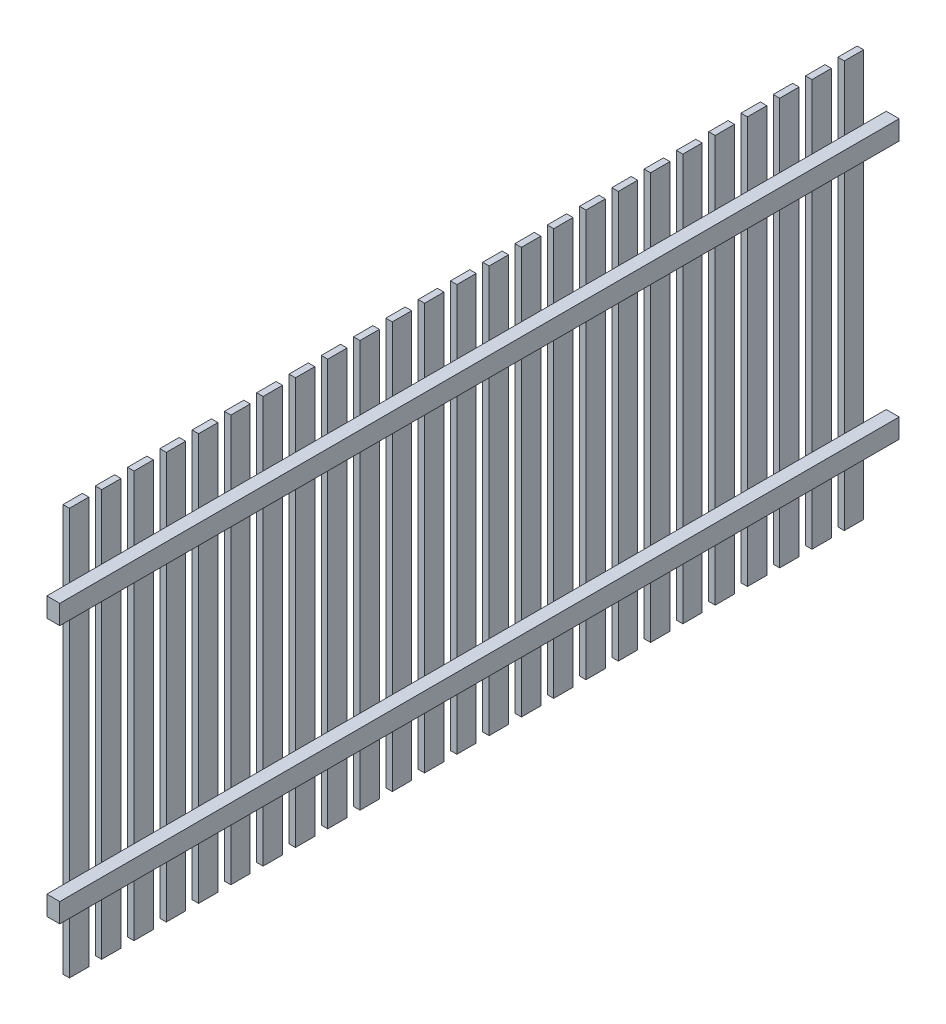
from build123d import *

# Parameters (mm, degrees)
SKIZZE1_W                       = 40
SKIZZE1_H                       = 60
AUFSATZ_LINEAR_AUSTRAGEN1_DEPTH = 1300
LINEARES_MUSTER1_COUNT          = 2
LINEARES_MUSTER1_PITCH          = 800
SKIZZE2_W                       = 60
SKIZZE2_H                       = 1260
AUFSATZ_LINEAR_AUSTRAGEN2_DEPTH = 20
LINEARES_MUSTER2_COUNT          = 13
LINEARES_MUSTER2_PITCH          = 100
LINEARES_MUSTER2_2_COUNT        = 13
LINEARES_MUSTER2_2_PITCH        = 100


with BuildPart() as part:
    # Skizze1 → Aufsatz-Linear austragen1 (new body, symmetric)
    with BuildSketch(Plane.XY):
        with Locations((20, 30)):
            Rectangle(SKIZZE1_W, SKIZZE1_H)
    extrude(amount=AUFSATZ_LINEAR_AUSTRAGEN1_DEPTH, both=True)


with BuildPart() as lineares_muster1_1:
    # Lineares Muster1: pattern copy
    add(part.part.moved(Location(Vector(0, 1, 0) * (1 * LINEARES_MUSTER1_PITCH))))


with BuildPart() as body_3:
    # Skizze2 → Aufsatz-Linear austragen2 (new body)
    with BuildSketch(Plane.ZY):
        with Locations((0, 430)):
            Rectangle(SKIZZE2_W, SKIZZE2_H)
    extrude(amount=AUFSATZ_LINEAR_AUSTRAGEN2_DEPTH)


with BuildPart() as lineares_muster2_1:
    # Lineares Muster2: pattern copy
    add(body_3.part.moved(Location(Vector(0, 0, 1) * (1 * LINEARES_MUSTER2_PITCH))))


with BuildPart() as lineares_muster2_2:
    # Lineares Muster2: pattern copy
    add(body_3.part.moved(Location(Vector(0, 0, 1) * (2 * LINEARES_MUSTER2_PITCH))))


with BuildPart() as lineares_muster2_3:
    # Lineares Muster2: pattern copy
    add(body_3.part.moved(Location(Vector(0, 0, 1) * (3 * LINEARES_MUSTER2_PITCH))))


with BuildPart() as lineares_muster2_4:
    # Lineares Muster2: pattern copy
    add(body_3.part.moved(Location(Vector(0, 0, 1) * (4 * LINEARES_MUSTER2_PITCH))))


with BuildPart() as lineares_muster2_5:
    # Lineares Muster2: pattern copy
    add(body_3.part.moved(Location(Vector(0, 0, 1) * (5 * LINEARES_MUSTER2_PITCH))))


with BuildPart() as lineares_muster2_6:
    # Lineares Muster2: pattern copy
    add(body_3.part.moved(Location(Vector(0, 0, 1) * (6 * LINEARES_MUSTER2_PITCH))))


with BuildPart() as lineares_muster2_7:
    # Lineares Muster2: pattern copy
    add(body_3.part.moved(Location(Vector(0, 0, 1) * (7 * LINEARES_MUSTER2_PITCH))))


with BuildPart() as lineares_muster2_8:
    # Lineares Muster2: pattern copy
    add(body_3.part.moved(Location(Vector(0, 0, 1) * (8 * LINEARES_MUSTER2_PITCH))))


with BuildPart() as lineares_muster2_9:
    # Lineares Muster2: pattern copy
    add(body_3.part.moved(Location(Vector(0, 0, 1) * (9 * LINEARES_MUSTER2_PITCH))))


with BuildPart() as lineares_muster2_10:
    # Lineares Muster2: pattern copy
    add(body_3.part.moved(Location(Vector(0, 0, 1) * (10 * LINEARES_MUSTER2_PITCH))))


with BuildPart() as lineares_muster2_11:
    # Lineares Muster2: pattern copy
    add(body_3.part.moved(Location(Vector(0, 0, 1) * (11 * LINEARES_MUSTER2_PITCH))))


with BuildPart() as lineares_muster2_12:
    # Lineares Muster2: pattern copy
    add(body_3.part.moved(Location(Vector(0, 0, 1) * (12 * LINEARES_MUSTER2_PITCH))))


with BuildPart() as lineares_muster2_2_1:
    # Lineares Muster2 2: pattern copy
    add(body_3.part.moved(Location(Vector(0, 0, -1) * (1 * LINEARES_MUSTER2_2_PITCH))))


with BuildPart() as lineares_muster2_2_2:
    # Lineares Muster2 2: pattern copy
    add(body_3.part.moved(Location(Vector(0, 0, -1) * (2 * LINEARES_MUSTER2_2_PITCH))))


with BuildPart() as lineares_muster2_2_3:
    # Lineares Muster2 2: pattern copy
    add(body_3.part.moved(Location(Vector(0, 0, -1) * (3 * LINEARES_MUSTER2_2_PITCH))))


with BuildPart() as lineares_muster2_2_4:
    # Lineares Muster2 2: pattern copy
    add(body_3.part.moved(Location(Vector(0, 0, -1) * (4 * LINEARES_MUSTER2_2_PITCH))))


with BuildPart() as lineares_muster2_2_5:
    # Lineares Muster2 2: pattern copy
    add(body_3.part.moved(Location(Vector(0, 0, -1) * (5 * LINEARES_MUSTER2_2_PITCH))))


with BuildPart() as lineares_muster2_2_6:
    # Lineares Muster2 2: pattern copy
    add(body_3.part.moved(Location(Vector(0, 0, -1) * (6 * LINEARES_MUSTER2_2_PITCH))))


with BuildPart() as lineares_muster2_2_7:
    # Lineares Muster2 2: pattern copy
    add(body_3.part.moved(Location(Vector(0, 0, -1) * (7 * LINEARES_MUSTER2_2_PITCH))))


with BuildPart() as lineares_muster2_2_8:
    # Lineares Muster2 2: pattern copy
    add(body_3.part.moved(Location(Vector(0, 0, -1) * (8 * LINEARES_MUSTER2_2_PITCH))))


with BuildPart() as lineares_muster2_2_9:
    # Lineares Muster2 2: pattern copy
    add(body_3.part.moved(Location(Vector(0, 0, -1) * (9 * LINEARES_MUSTER2_2_PITCH))))


with BuildPart() as lineares_muster2_2_10:
    # Lineares Muster2 2: pattern copy
    add(body_3.part.moved(Location(Vector(0, 0, -1) * (10 * LINEARES_MUSTER2_2_PITCH))))


with BuildPart() as lineares_muster2_2_11:
    # Lineares Muster2 2: pattern copy
    add(body_3.part.moved(Location(Vector(0, 0, -1) * (11 * LINEARES_MUSTER2_2_PITCH))))


with BuildPart() as lineares_muster2_2_12:
    # Lineares Muster2 2: pattern copy
    add(body_3.part.moved(Location(Vector(0, 0, -1) * (12 * LINEARES_MUSTER2_2_PITCH))))


solid = Compound([part.part, lineares_muster1_1.part, body_3.part, lineares_muster2_1.part, lineares_muster2_2.part, lineares_muster2_3.part, lineares_muster2_4.part, lineares_muster2_5.part, lineares_muster2_6.part, lineares_muster2_7.part, lineares_muster2_8.part, lineares_muster2_9.part, lineares_muster2_10.part, lineares_muster2_11.part, lineares_muster2_12.part, lineares_muster2_2_1.part, lineares_muster2_2_2.part, lineares_muster2_2_3.part, lineares_muster2_2_4.part, lineares_muster2_2_5.part, lineares_muster2_2_6.part, lineares_muster2_2_7.part, lineares_muster2_2_8.part, lineares_muster2_2_9.part, lineares_muster2_2_10.part, lineares_muster2_2_11.part, lineares_muster2_2_12.part])
